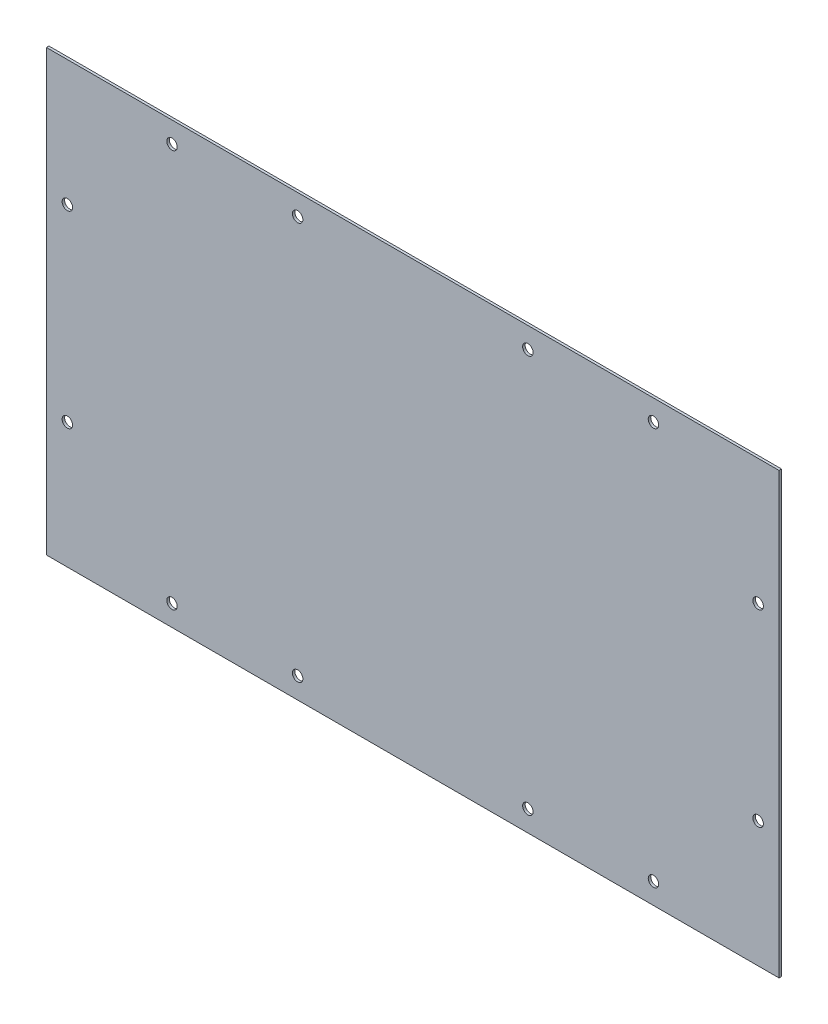
from build123d import *

# Parameters (mm, degrees)
SURFACE_EXTRUDE1_1_DEPTH = 350
THICKEN2_T1              = 1.2
SKETCH2_R                = 2.5
CUT_EXTRUDE1_DEPTH       = 10


with BuildPart() as body_1:
    # Surface-Extrude1: a surface, the sketch's curves swept straight by 350 mm
    with BuildLine(Plane(origin=(0, 0, 0), x_dir=(0, 0, -1), z_dir=(1, 0, 0)), mode=Mode.PRIVATE) as surface_extrude1_1_path:
        Line((0, 0), (0, 210))
    surface_extrude1_1 = Shell.extrude(surface_extrude1_1_path.wire(), (1 * SURFACE_EXTRUDE1_1_DEPTH, 0 * SURFACE_EXTRUDE1_1_DEPTH, 0 * SURFACE_EXTRUDE1_1_DEPTH))
    add(Solid.thicken(surface_extrude1_1, THICKEN2_T1))

    # Sketch2 → Cut-Extrude1 (cut)
    with BuildSketch(Plane(origin=(0, 0, 0), x_dir=(-1, 0, 0), z_dir=(0, 0, -1))):
        with Locations((-340, 150)):
            Circle(SKETCH2_R)
        with Locations((-290, 200)):
            Circle(SKETCH2_R)
        with Locations((-230, 200)):
            Circle(SKETCH2_R)
        with Locations((-10, 150)):
            Circle(SKETCH2_R)
        with Locations((-120, 200)):
            Circle(SKETCH2_R)
        with Locations((-60, 200)):
            Circle(SKETCH2_R)
        with Locations((-10, 60)):
            Circle(SKETCH2_R)
        with Locations((-60, 10)):
            Circle(SKETCH2_R)
        with Locations((-120, 10)):
            Circle(SKETCH2_R)
        with Locations((-230, 10)):
            Circle(SKETCH2_R)
        with Locations((-290, 10)):
            Circle(SKETCH2_R)
        with Locations((-340, 60)):
            Circle(SKETCH2_R)
    extrude(amount=-CUT_EXTRUDE1_DEPTH, mode=Mode.SUBTRACT)


solid = body_1.part
